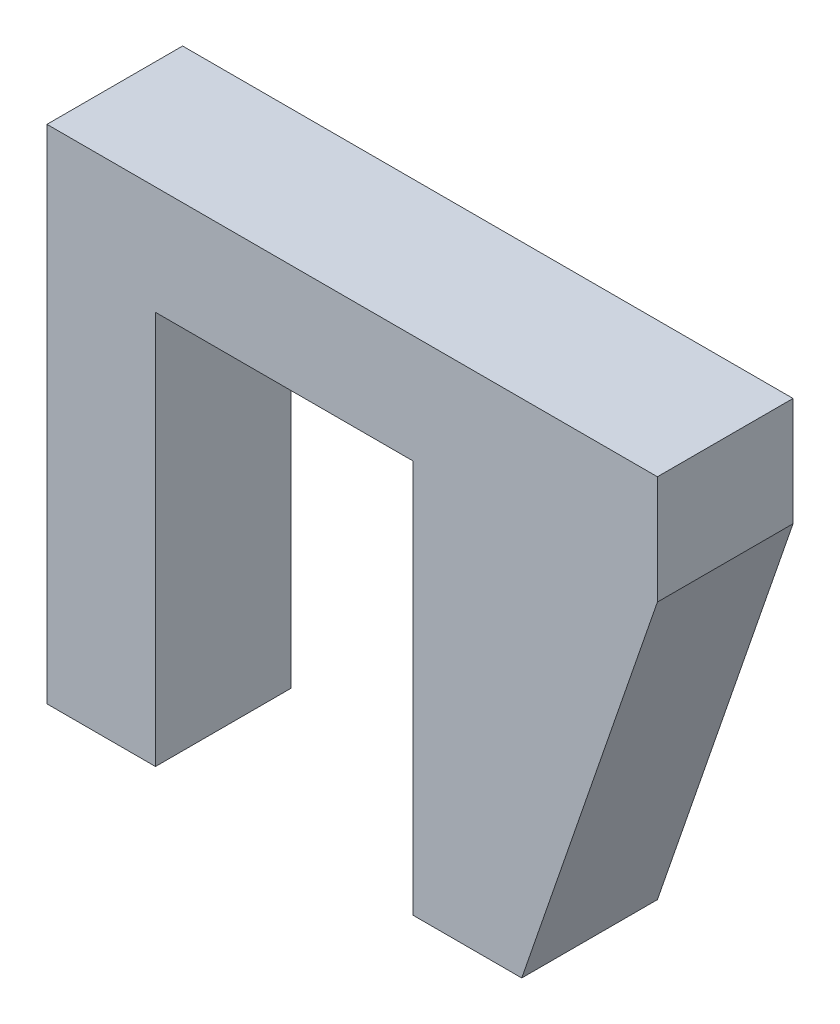
from build123d import *

# Parameters (mm, degrees)
BOSS_EXTRUDE1_DEPTH = 5


with BuildPart() as part:
    # Sketch1 → Boss-Extrude1 (new body)
    with BuildSketch(Plane.XY):
        Polygon((-4.75, -4.75), (-4.75, -9.75), (-8.75, -9.75), (-8.75, 8.75), (8.75, 8.75), (13.75, 8.75), (13.75, 4.75), (8.75, -9.75), (4.75, -9.75), (4.75, -4.75), (4.75, 4.75), (-4.75, 4.75), align=None)
    extrude(amount=BOSS_EXTRUDE1_DEPTH)


solid = part.part
